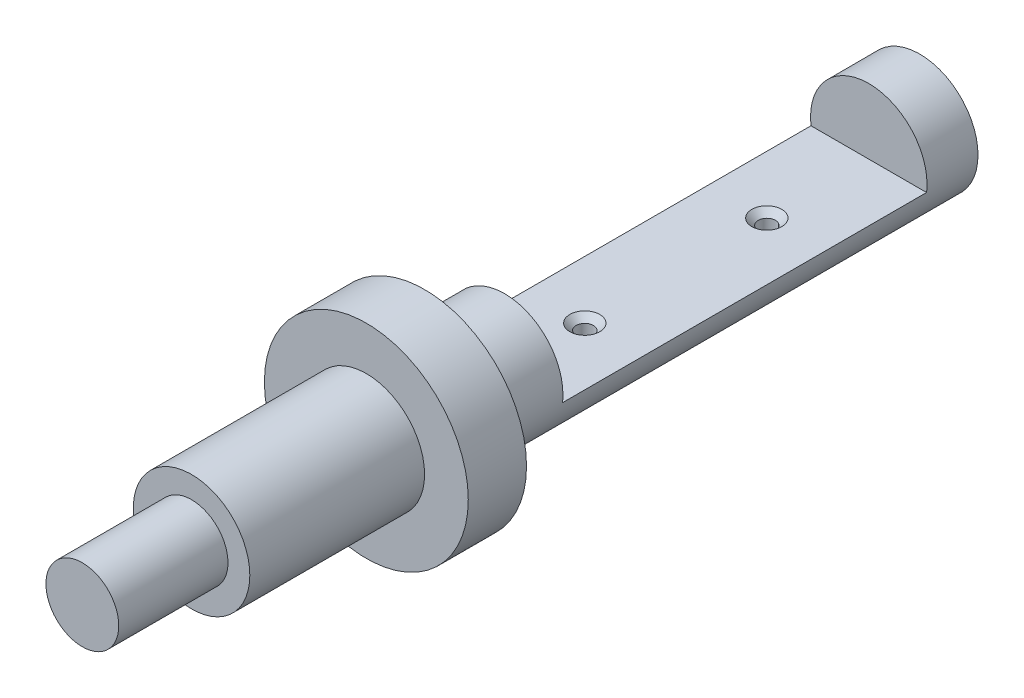
from build123d import *

# Parameters (mm, degrees)
SKETCH1_R                       = 8
BOSS_EXTRUDE1_DEPTH             = 34
SKETCH2_R                       = 14
BOSS_EXTRUDE2_DEPTH             = 8
SKETCH3_R                       = 8
BOSS_EXTRUDE3_DEPTH             = 24
SKETCH4_R                       = 5
BOSS_EXTRUDE4_DEPTH             = 15
SKETCH5_W                       = 50
SKETCH5_H                       = 13.172720446
CUT_EXTRUDE1_DEPTH              = 15
CUT_EXTRUDE1_DEPTH_BACK         = 15
F_4_48_TAPPED_HOLE1_D           = 2.3749
F_4_48_TAPPED_HOLE1_DEPTH       = 10.35
F_4_48_TAPPED_HOLE1_CSINK_D     = 4.1148
F_4_48_TAPPED_HOLE1_CSINK_ANGLE = 90
F_4_48_TAPPED_HOLE1_TIP         = 0.713491942


with BuildPart() as part:
    # Sketch1 → Boss-Extrude1 (new body, symmetric)
    with BuildSketch(Plane.XY):
        Circle(SKETCH1_R)
    extrude(amount=BOSS_EXTRUDE1_DEPTH, both=True)

    # Sketch2 → Boss-Extrude2 (add)
    with BuildSketch(Plane.XY.offset(34)):
        Circle(SKETCH2_R)
    extrude(amount=BOSS_EXTRUDE2_DEPTH)

    # Sketch3 → Boss-Extrude3 (add)
    with BuildSketch(Plane.XY.offset(42)):
        Circle(SKETCH3_R)
    extrude(amount=BOSS_EXTRUDE3_DEPTH)

    # Sketch4 → Boss-Extrude4 (add)
    with BuildSketch(Plane.XY.offset(66)):
        Circle(SKETCH4_R)
    extrude(amount=BOSS_EXTRUDE4_DEPTH)

    # Sketch5 → Cut-Extrude1 (cut, two sides)
    with BuildSketch(Plane(origin=(0, 0, 0), x_dir=(0, 0, -1), z_dir=(1, 0, 0))) as cut_extrude1_sk:
        with Locations((2, 5.586360223)):
            Rectangle(SKETCH5_W, SKETCH5_H)
    extrude(amount=CUT_EXTRUDE1_DEPTH, mode=Mode.SUBTRACT)
    extrude(cut_extrude1_sk.sketch, amount=-CUT_EXTRUDE1_DEPTH_BACK, mode=Mode.SUBTRACT)

    # #4-48 Tapped Hole1
    with Locations(Plane(origin=(0, -1, 0), x_dir=(1, 0, 0), z_dir=(0, 1, 0))):
        with Locations((0, -12), (0, 13)):
            CounterSinkHole(F_4_48_TAPPED_HOLE1_D / 2, F_4_48_TAPPED_HOLE1_CSINK_D / 2, depth=F_4_48_TAPPED_HOLE1_DEPTH, counter_sink_angle=F_4_48_TAPPED_HOLE1_CSINK_ANGLE)
            with Locations((0, 0, -(F_4_48_TAPPED_HOLE1_DEPTH + F_4_48_TAPPED_HOLE1_TIP / 2))):  # 118° drill point
                Cone(0, F_4_48_TAPPED_HOLE1_D / 2, F_4_48_TAPPED_HOLE1_TIP, mode=Mode.SUBTRACT)


solid = part.part
